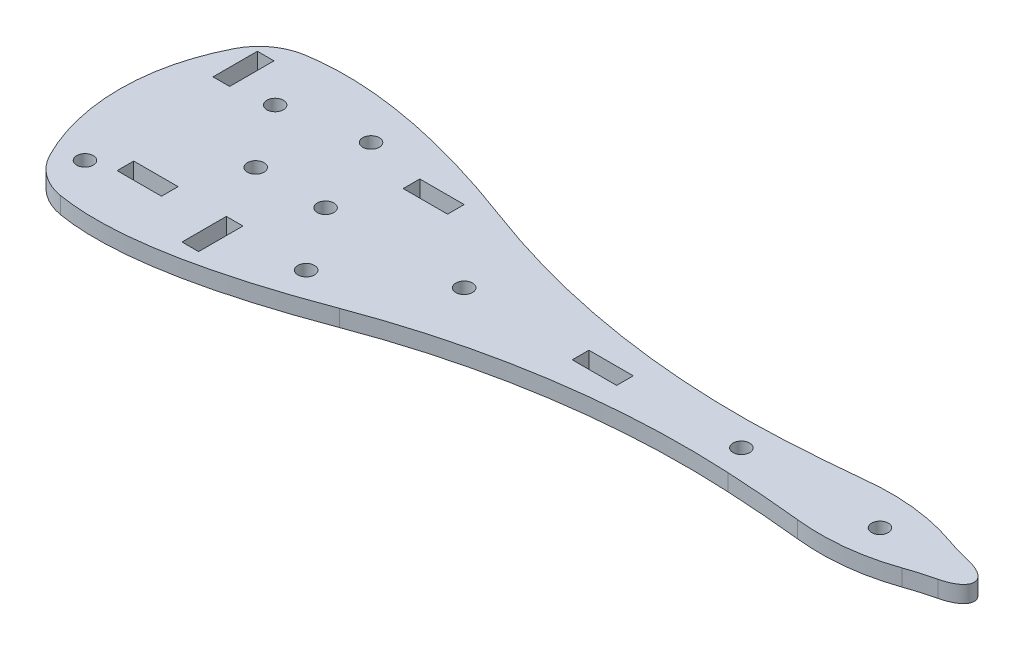
from build123d import *

# Parameters (mm, degrees)
ESBO_O1_R                = 1.5
ESBO_O1_W                = 3
ESBO_O1_H                = 8
ESBO_O1_W_2              = 8
ESBO_O1_H_2              = 3
RESSALTO_EXTRUS_O1_DEPTH = 3


with BuildPart() as part:
    # Esboço1 → Ressalto-extrusão1 (new body)
    with BuildSketch(Plane(origin=(0, 0, 0), x_dir=(1, 0, 0), z_dir=(0, 1, 0))):
        with BuildLine():
            ThreePointArc((-19.544028008, 21.987058404), (-23.767751262, 20.202130438), (-26.75078073, 16.719697214))
            ThreePointArc((-26.75078073, 16.719697214), (-30.815641586, -2.3e-07), (-26.750780519, -16.719697622))
            ThreePointArc((-26.750780519, -16.719697622), (-23.767751269, -20.202130616), (-19.544028371, -21.987058612))
            add(Edge.make_bspline(
                [(23.247280819, -14.466941833), (22.21541658, -14.85491506), (7.843575487, -20.128766531), (-8.032505645, -23.945383183), (-19.544028371, -21.987058612)],
                knots=[0.1894974, 0.1894974, 0.1894974, 0.1894974, 0.216439611, 0.561126756, 0.561126756, 0.561126756, 0.561126756], degree=3))
            ThreePointArc((23.247280819, -14.466941833), (53.114593998, -6.632399806), (83.953283265, -5.079438247))
            add(Edge.make_bspline(
                [(97.598521861, -6.15), (93.039003458, -5.676054912), (88.490590593, -5.319200994), (83.953283265, -5.079438247)],
                knots=[0, 0, 0, 0, 0.137959586, 0.137959586, 0.137959586, 0.137959586], degree=3))
            add(Edge.make_bspline(
                [(114.569723425, -4.259468977), (109.134912936, -6.157348784), (103.477845748, -6.787525792), (97.598521861, -6.15)],
                knots=[0.35388944, 0.35388944, 0.35388944, 0.35388944, 1, 1, 1, 1], degree=3))
            ThreePointArc((114.569723425, -4.259468977), (117.037611185, -3.468795912), (119.543150354, -2.807050219))
            add(Edge.make_bspline(
                [(119.543150354, -2.807050219), (131.408766059, 0), (119.543150354, 2.807050219)],
                knots=[5.194112445, 5.194112445, 5.194112445, 7.372258169, 7.372258169, 7.372258169], degree=2, weights=[1, 0.463307193, 1]))
            ThreePointArc((119.543150354, 2.807050219), (117.037611185, 3.468795912), (114.569723425, 4.259468977))
            add(Edge.make_bspline(
                [(114.569723425, 4.259468977), (109.134912936, 6.157348784), (103.477845748, 6.787525792), (97.598521861, 6.15)],
                knots=[0.35388944, 0.35388944, 0.35388944, 0.35388944, 1, 1, 1, 1], degree=3))
            add(Edge.make_bspline(
                [(97.598521861, 6.15), (93.039003574, 5.676054924), (88.490590825, 5.319201013), (83.953283612, 5.079438265)],
                knots=[0, 0, 0, 0, 0.137959582, 0.137959582, 0.137959582, 0.137959582], degree=3))
            ThreePointArc((83.953283612, 5.079438265), (53.114594943, 6.632399691), (23.24728229, 14.466941345))
            add(Edge.make_bspline(
                [(23.24728229, 14.466941345), (22.21541757, 14.854914742), (7.843576153, 20.128766099), (-8.032505406, 23.945382333), (-19.544028008, 21.987058404)],
                knots=[0.189497388, 0.189497388, 0.189497388, 0.189497388, 0.216439611, 0.561126752, 0.561126752, 0.561126752, 0.561126752], degree=3))
        make_face()
        with Locations((-22.8, -14.3)):
            Circle(ESBO_O1_R, mode=Mode.SUBTRACT)
        with Locations((0.2, -14.3)):
            Rectangle(ESBO_O1_W, ESBO_O1_H, mode=Mode.SUBTRACT)
        with Locations((-14.3, -11.5)):
            Rectangle(ESBO_O1_W_2, ESBO_O1_H_2, mode=Mode.SUBTRACT)
        with Locations((14.3, -11.5)):
            Circle(ESBO_O1_R, mode=Mode.SUBTRACT)
        with Locations((-6.3, 0)):
            Circle(ESBO_O1_R, mode=Mode.SUBTRACT)
        with Locations((6.3, 0)):
            Circle(ESBO_O1_R, mode=Mode.SUBTRACT)
        with Locations((-14.3, 11.5)):
            Circle(ESBO_O1_R, mode=Mode.SUBTRACT)
        with Locations((31.3, 0)):
            Circle(ESBO_O1_R, mode=Mode.SUBTRACT)
        with Locations((14.3, 11.500000009)):
            Rectangle(ESBO_O1_W_2, ESBO_O1_H_2, mode=Mode.SUBTRACT)
        with Locations((-22.8, 14.3)):
            Rectangle(ESBO_O1_W, ESBO_O1_H, mode=Mode.SUBTRACT)
        with Locations((0.2, 14.3)):
            Circle(ESBO_O1_R, mode=Mode.SUBTRACT)
        Polygon((60.3, -1.5), (56.3, -1.5), (52.3, -1.5), (52.3, 1.5), (60.3, 1.5), align=None, mode=Mode.SUBTRACT)
        with Locations((81.3, 0)):
            Circle(ESBO_O1_R, mode=Mode.SUBTRACT)
        with Locations((106.3, 0)):
            Circle(ESBO_O1_R, mode=Mode.SUBTRACT)
    extrude(amount=RESSALTO_EXTRUS_O1_DEPTH)


solid = part.part
